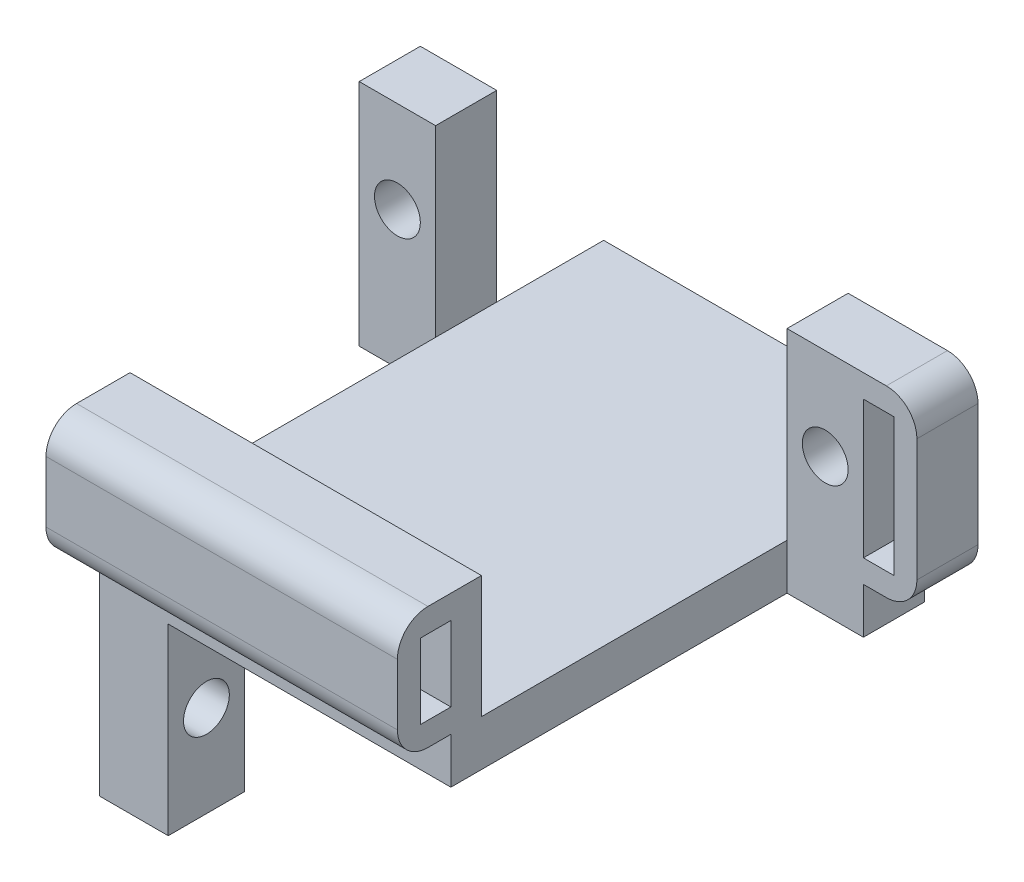
from build123d import *

# Parameters (mm, degrees)
BOSS_EXTRUDE1_DEPTH = 3
SKETCH3_W           = 4.5
SKETCH3_H           = 5
BOSS_EXTRUDE2_DEPTH = 12
SKETCH4_W           = 5
SKETCH4_H           = 4
BOSS_EXTRUDE3_DEPTH = 12
SKETCH5_R           = 1.5
CUT_EXTRUDE1_DEPTH  = 12
SKETCH6_R           = 1.5
CUT_EXTRUDE2_DEPTH  = 12
SKETCH7_W           = 23
SKETCH7_H           = 5.5
BOSS_EXTRUDE5_DEPTH = 8
SKETCH8_W           = 2
SKETCH8_H           = 4.9
CUT_EXTRUDE3_DEPTH  = 28
FILLET1_R           = 2
SKETCH11_W          = 4
SKETCH11_H          = 12
BOSS_EXTRUDE6_DEPTH = 3.5
SKETCH12_W          = 2
SKETCH12_H          = 9
CUT_EXTRUDE5_DEPTH  = 10
FILLET3_R           = 2


with BuildPart() as part:
    # Sketch2 → Boss-Extrude1 (new body)
    with BuildSketch(Plane(origin=(0, 0, 0), x_dir=(1, 0, 0), z_dir=(0, 1, 0))):
        Polygon((-11.5, 5.5), (-11.5, -16.5), (11.5, -16.5), (11.5, 5.5), (16.5, 5.5), (16.5, 9.5), (11.5, 9.5), (11.5, 16.5), (-11.5, 16.5), (-11.5, 9.5), (-16.5, 9.5), (-16.5, 5.5), align=None)
    extrude(amount=BOSS_EXTRUDE1_DEPTH)

    # Sketch3 → Boss-Extrude2 (add)
    with BuildSketch(Plane.XZ):
        with Locations((-9.25, 14)):
            Rectangle(SKETCH3_W, SKETCH3_H)
        with Locations((-9.25, -14)):
            Rectangle(SKETCH3_W, SKETCH3_H)
    extrude(amount=BOSS_EXTRUDE2_DEPTH)

    # Sketch4 → Boss-Extrude3 (add)
    with BuildSketch(Plane(origin=(0, 3, 0), x_dir=(1, 0, 0), z_dir=(0, 1, 0))):
        with Locations((-14, 7.5)):
            Rectangle(SKETCH4_W, SKETCH4_H)
        with Locations((14, 7.5)):
            Rectangle(SKETCH4_W, SKETCH4_H)
    extrude(amount=BOSS_EXTRUDE3_DEPTH)

    # Sketch5 → Cut-Extrude1 (cut)
    with BuildSketch(Plane.XY.offset(-5.5)):
        with Locations((14, 9)):
            Circle(SKETCH5_R)
        with Locations((-14, 9)):
            Circle(SKETCH5_R)
    extrude(amount=-CUT_EXTRUDE1_DEPTH, mode=Mode.SUBTRACT)

    # Sketch6 → Cut-Extrude2 (cut)
    with BuildSketch(Plane(origin=(-7, 0, 0), x_dir=(0, 0, -1), z_dir=(1, 0, 0))):
        with Locations((-14, -6)):
            Circle(SKETCH6_R)
        with Locations((14, -6)):
            Circle(SKETCH6_R)
    extrude(amount=-CUT_EXTRUDE2_DEPTH, mode=Mode.SUBTRACT)

    # Sketch7 → Boss-Extrude5 (add)
    with BuildSketch(Plane(origin=(0, 3, 0), x_dir=(1, 0, 0), z_dir=(0, 1, 0))):
        with Locations((0, -17.25)):
            Rectangle(SKETCH7_W, SKETCH7_H)
    extrude(amount=BOSS_EXTRUDE5_DEPTH)

    # Sketch8 → Cut-Extrude3 (cut)
    with BuildSketch(Plane.ZY.offset(11.5)):
        with Locations((17.5, 7)):
            Rectangle(SKETCH8_W, SKETCH8_H)
    extrude(amount=-CUT_EXTRUDE3_DEPTH, mode=Mode.SUBTRACT)

    # Fillet1
    fillet1_edges = [part.edges().sort_by_distance(p)[0] for p in [
        (0, 3, 20),
        (0, 11, 20),
    ]]
    fillet(fillet1_edges, radius=FILLET1_R)

    # Sketch11 → Boss-Extrude6 (add)
    with BuildSketch(Plane(origin=(16.5, 0, 0), x_dir=(0, 0, -1), z_dir=(1, 0, 0))):
        with Locations((7.5, 9)):
            Rectangle(SKETCH11_W, SKETCH11_H)
    extrude(amount=BOSS_EXTRUDE6_DEPTH)

    # Sketch12 → Cut-Extrude5 (cut)
    with BuildSketch(Plane.XY.offset(-5.5)):
        with Locations((17.5, 9)):
            Rectangle(SKETCH12_W, SKETCH12_H)
    extrude(amount=-CUT_EXTRUDE5_DEPTH, mode=Mode.SUBTRACT)

    # Fillet3
    fillet3_edges = [part.edges().sort_by_distance(p)[0] for p in [
        (20, 3, -7.5),
        (20, 15, -7.5),
    ]]
    fillet(fillet3_edges, radius=FILLET3_R)


solid = part.part
